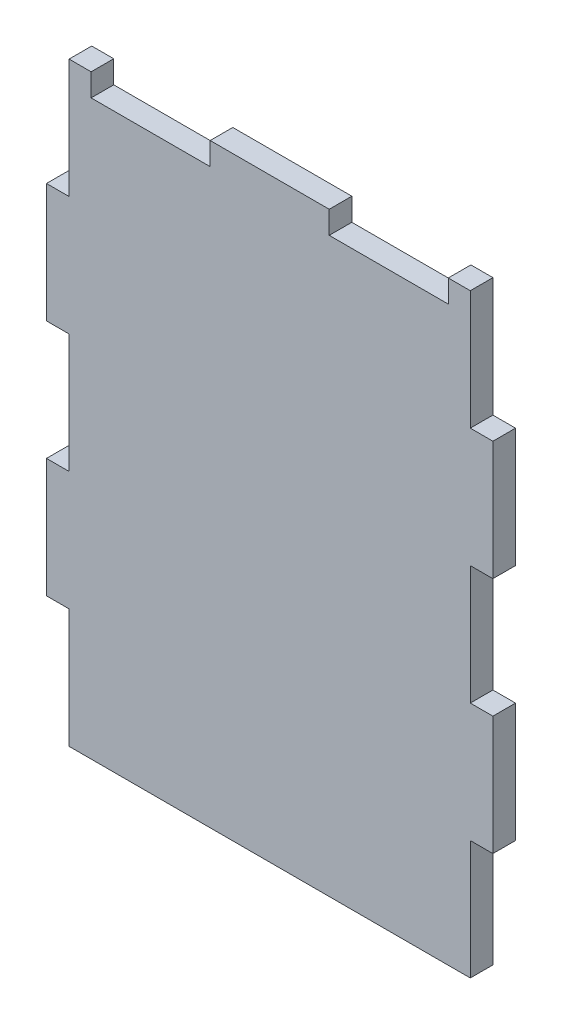
from build123d import *

# Parameters (mm, degrees)
BOSS_EXTRUDE1_DEPTH = 4.826
SKETCH2_W           = 25.4
SKETCH2_H           = 4.826
CUT_EXTRUDE1_DEPTH  = 4.826


with BuildPart() as part:
    # Sketch1 → Boss-Extrude1 (new body)
    with BuildSketch(Plane.XY):
        Polygon((0, 76.2), (0, 101.6), (4.826, 101.6), (4.826, 127), (90.424, 127), (90.424, 101.6), (95.25, 101.6), (95.25, 76.2), (90.424, 76.2), (90.424, 50.8), (95.25, 50.8), (95.25, 25.4), (90.424, 25.4), (90.424, 0), (4.826, 0), (4.826, 25.4), (0, 25.4), (0, 50.8), (4.826, 50.8), (4.826, 76.2), align=None)
    extrude(amount=BOSS_EXTRUDE1_DEPTH)

    # Sketch2 → Cut-Extrude1 (cut)
    with BuildSketch(Plane(origin=(0, 127, 0), x_dir=(1, 0, 0), z_dir=(0, 1, 0))):
        with Locations((73.025, -2.413)):
            Rectangle(SKETCH2_W, SKETCH2_H)
        with Locations((22.225, -2.413)):
            Rectangle(SKETCH2_W, SKETCH2_H)
    extrude(amount=-CUT_EXTRUDE1_DEPTH, mode=Mode.SUBTRACT)


solid = part.part
